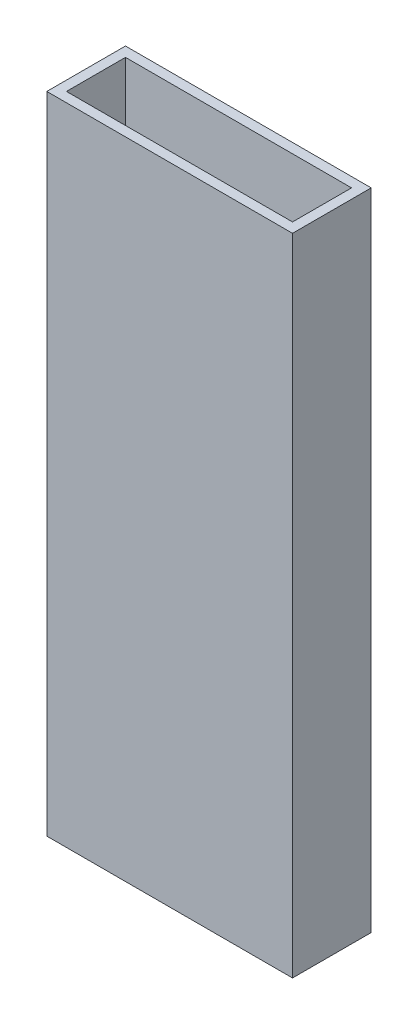
from build123d import *

# Parameters (mm, degrees)
SKETCH1_W           = 76.2
SKETCH1_H           = 24.4
SKETCH1_W_2         = 70.104
SKETCH1_H_2         = 18.304
BOSS_EXTRUDE1_DEPTH = 200


with BuildPart() as part:
    # Sketch1 → Boss-Extrude1 (new body)
    with BuildSketch(Plane(origin=(0, 0, 0), x_dir=(1, 0, 0), z_dir=(0, 1, 0))):
        Rectangle(SKETCH1_W, SKETCH1_H)
        Rectangle(SKETCH1_W_2, SKETCH1_H_2, mode=Mode.SUBTRACT)
    extrude(amount=BOSS_EXTRUDE1_DEPTH)


solid = part.part
